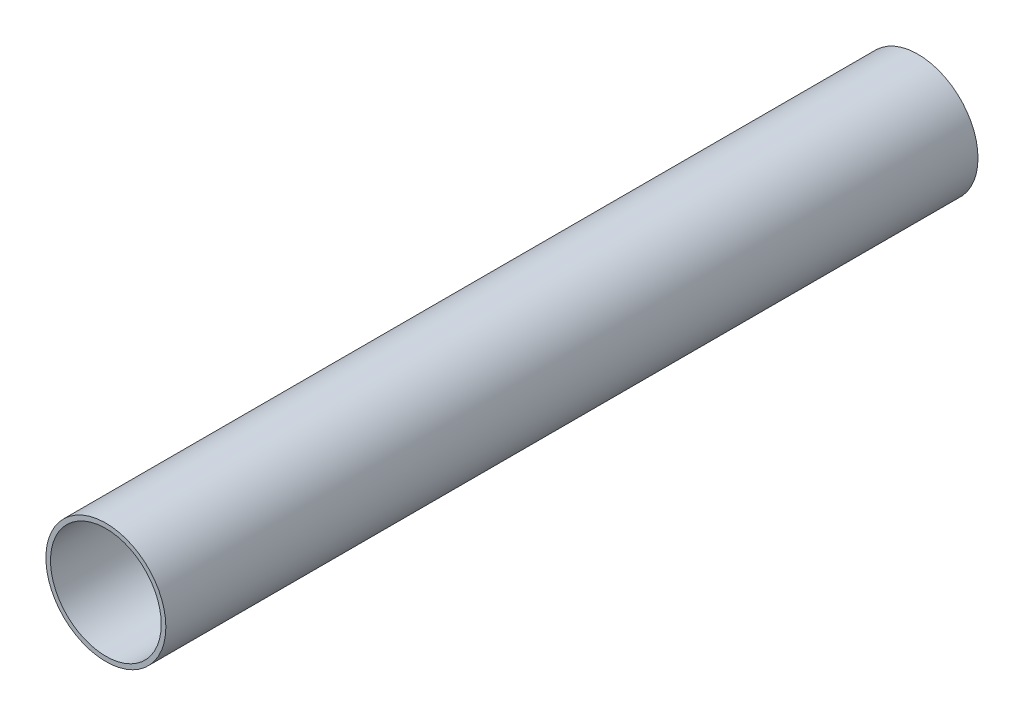
from build123d import *

# Parameters (mm, degrees)
SKETCH1_R           = 20.6375
SKETCH1_R_2         = 19.05
BOSS_EXTRUDE1_DEPTH = 279.4


with BuildPart() as part:
    # Sketch1 → Boss-Extrude1 (new body)
    with BuildSketch(Plane.XY):
        Circle(SKETCH1_R)
        Circle(SKETCH1_R_2, mode=Mode.SUBTRACT)
    extrude(amount=BOSS_EXTRUDE1_DEPTH)


solid = part.part
